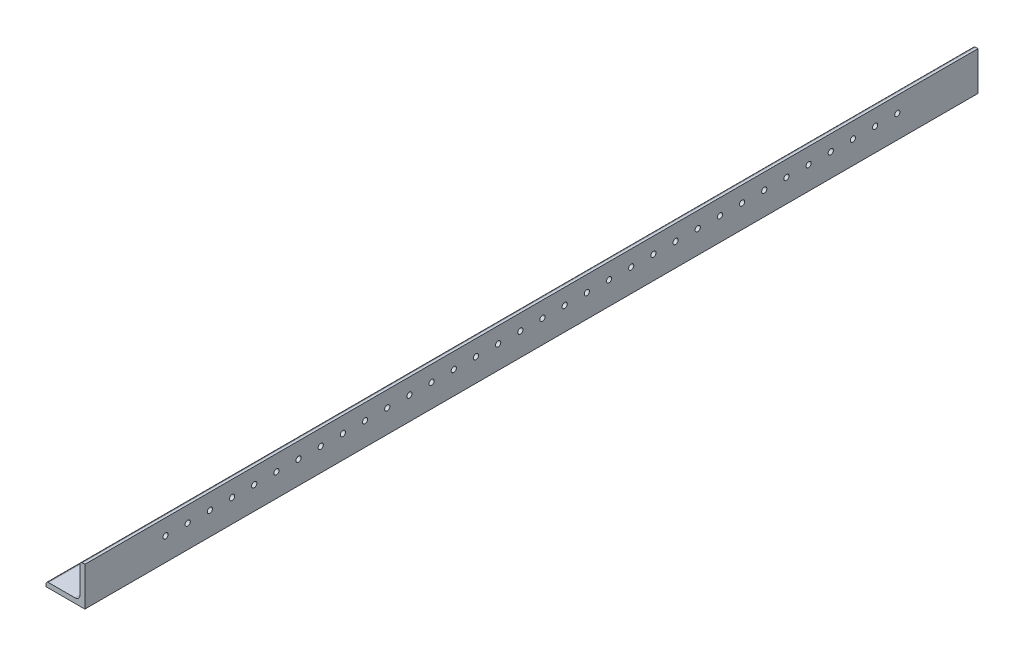
from build123d import *

# Parameters (mm, degrees)
BOSS_EXTRUDE1_DEPTH = 609.6
SKETCH3_W           = 635.2
SKETCH3_H           = 25.4
CUT_EXTRUDE2_DEPTH  = 30.48
SKETCH5_R           = 1.7
CUT_EXTRUDE3_DEPTH  = 611.137198198
SKETCH7_R           = 1.7
CUT_EXTRUDE4_DEPTH  = 611.137198198


with BuildPart() as part:
    # Sketch2 → Boss-Extrude1 (new, symmetric)
    with BuildSketch(Plane.XY):
        with BuildLine():
            Line((-12.7, -12.7), (12.7, -12.7))
            Line((12.7, -12.7), (12.7, 12.7))
            Line((12.7, 12.7), (11.1125, 12.7))
            ThreePointArc((11.1125, 12.7), (9.989967985, 12.235032015), (9.525, 11.1125))
            Line((9.525, 11.1125), (9.525, -6.35))
            ThreePointArc((9.525, -6.35), (8.59506403, -8.59506403), (6.35, -9.525))
            Line((6.35, -9.525), (-11.1125, -9.525))
            ThreePointArc((-11.1125, -9.525), (-12.235032015, -9.989967985), (-12.7, -11.1125))
            Line((-12.7, -11.1125), (-12.7, -12.7))
        make_face()
    extrude(amount=BOSS_EXTRUDE1_DEPTH, both=True)

    # Sketch3 → Cut-Extrude2 (cut)
    with BuildSketch(Plane(origin=(12.7, 0, 0), x_dir=(0, 0, -1), z_dir=(1, 0, 0))):
        with Locations((292, 0)):
            Rectangle(SKETCH3_W, SKETCH3_H)
    extrude(amount=-CUT_EXTRUDE2_DEPTH, mode=Mode.SUBTRACT)

    # Sketch5 → Cut-Extrude3 (cut, through all)
    with BuildSketch(Plane.ZY.offset(-9.525)):
        with Locations(Location((78.35, 2.38125, 0), (0, 0, 270))):
            Circle(SKETCH5_R)
        with Locations(Location((92.85, 2.38125, 0), (0, 0, 270))):
            Circle(SKETCH5_R)
        with Locations(Location((107.35, 2.38125, 0), (0, 0, 270))):
            Circle(SKETCH5_R)
        with Locations(Location((121.85, 2.38125, 0), (0, 0, 270))):
            Circle(SKETCH5_R)
        with Locations(Location((136.35, 2.38125, 0), (0, 0, 270))):
            Circle(SKETCH5_R)
        with Locations(Location((150.85, 2.38125, 0), (0, 0, 270))):
            Circle(SKETCH5_R)
        with Locations(Location((165.35, 2.38125, 0), (0, 0, 270))):
            Circle(SKETCH5_R)
        with Locations(Location((179.85, 2.38125, 0), (0, 0, 270))):
            Circle(SKETCH5_R)
        with Locations(Location((194.35, 2.38125, 0), (0, 0, 270))):
            Circle(SKETCH5_R)
        with Locations(Location((208.85, 2.38125, 0), (0, 0, 270))):
            Circle(SKETCH5_R)
        with Locations(Location((223.35, 2.38125, 0), (0, 0, 270))):
            Circle(SKETCH5_R)
        with Locations(Location((237.85, 2.38125, 0), (0, 0, 270))):
            Circle(SKETCH5_R)
        with Locations(Location((252.35, 2.38125, 0), (0, 0, 270))):
            Circle(SKETCH5_R)
        with Locations(Location((266.85, 2.38125, 0), (0, 0, 270))):
            Circle(SKETCH5_R)
        with Locations(Location((281.35, 2.38125, 0), (0, 0, 270))):
            Circle(SKETCH5_R)
        with Locations(Location((295.85, 2.38125, 0), (0, 0, 270))):
            Circle(SKETCH5_R)
        with Locations(Location((310.35, 2.38125, 0), (0, 0, 270))):
            Circle(SKETCH5_R)
        with Locations(Location((324.85, 2.38125, 0), (0, 0, 270))):
            Circle(SKETCH5_R)
        with Locations(Location((339.35, 2.38125, 0), (0, 0, 270))):
            Circle(SKETCH5_R)
        with Locations(Location((353.85, 2.38125, 0), (0, 0, 270))):
            Circle(SKETCH5_R)
        with Locations(Location((368.35, 2.38125, 0), (0, 0, 270))):
            Circle(SKETCH5_R)
        with Locations(Location((382.85, 2.38125, 0), (0, 0, 270))):
            Circle(SKETCH5_R)
        with Locations(Location((397.35, 2.38125, 0), (0, 0, 270))):
            Circle(SKETCH5_R)
        with Locations(Location((411.85, 2.38125, 0), (0, 0, 270))):
            Circle(SKETCH5_R)
        with Locations(Location((426.35, 2.38125, 0), (0, 0, 270))):
            Circle(SKETCH5_R)
        with Locations(Location((440.85, 2.38125, 0), (0, 0, 270))):
            Circle(SKETCH5_R)
        with Locations(Location((455.35, 2.38125, 0), (0, 0, 270))):
            Circle(SKETCH5_R)
        with Locations(Location((469.85, 2.38125, 0), (0, 0, 270))):
            Circle(SKETCH5_R)
        with Locations(Location((484.35, 2.38125, 0), (0, 0, 270))):
            Circle(SKETCH5_R)
        with Locations(Location((498.85, 2.38125, 0), (0, 0, 270))):
            Circle(SKETCH5_R)
        with Locations(Location((513.35, 2.38125, 0), (0, 0, 270))):
            Circle(SKETCH5_R)
        with Locations(Location((527.85, 2.38125, 0), (0, 0, 270))):
            Circle(SKETCH5_R)
        with Locations(Location((542.35, 2.38125, 0), (0, 0, 270))):
            Circle(SKETCH5_R)
        with Locations(Location((556.85, 2.38125, 0), (0, 0, 270))):
            Circle(SKETCH5_R)
    extrude(amount=-CUT_EXTRUDE3_DEPTH, mode=Mode.SUBTRACT)

    # Sketch7 → Cut-Extrude4 (cut, through all)
    with BuildSketch(Plane(origin=(0, -9.525, 0), x_dir=(1, 0, 0), z_dir=(0, 1, 0))):
        with Locations(Location((-2.38125, -78.35, 0), (0, 0, 180))):
            Circle(SKETCH7_R)
        with Locations(Location((-2.38125, -92.85, 0), (0, 0, 180))):
            Circle(SKETCH7_R)
        with Locations(Location((-2.38125, -107.35, 0), (0, 0, 180))):
            Circle(SKETCH7_R)
        with Locations(Location((-2.38125, -121.85, 0), (0, 0, 180))):
            Circle(SKETCH7_R)
        with Locations(Location((-2.38125, -136.35, 0), (0, 0, 180))):
            Circle(SKETCH7_R)
        with Locations(Location((-2.38125, -150.85, 0), (0, 0, 180))):
            Circle(SKETCH7_R)
        with Locations(Location((-2.38125, -165.35, 0), (0, 0, 180))):
            Circle(SKETCH7_R)
        with Locations(Location((-2.38125, -179.85, 0), (0, 0, 180))):
            Circle(SKETCH7_R)
        with Locations(Location((-2.38125, -194.35, 0), (0, 0, 180))):
            Circle(SKETCH7_R)
        with Locations(Location((-2.38125, -208.85, 0), (0, 0, 180))):
            Circle(SKETCH7_R)
        with Locations(Location((-2.38125, -223.35, 0), (0, 0, 180))):
            Circle(SKETCH7_R)
        with Locations(Location((-2.38125, -237.85, 0), (0, 0, 180))):
            Circle(SKETCH7_R)
        with Locations(Location((-2.38125, -252.35, 0), (0, 0, 180))):
            Circle(SKETCH7_R)
        with Locations(Location((-2.38125, -266.85, 0), (0, 0, 180))):
            Circle(SKETCH7_R)
        with Locations(Location((-2.38125, -281.35, 0), (0, 0, 180))):
            Circle(SKETCH7_R)
        with Locations(Location((-2.38125, -295.85, 0), (0, 0, 180))):
            Circle(SKETCH7_R)
        with Locations(Location((-2.38125, -310.35, 0), (0, 0, 180))):
            Circle(SKETCH7_R)
        with Locations(Location((-2.38125, -324.85, 0), (0, 0, 180))):
            Circle(SKETCH7_R)
        with Locations(Location((-2.38125, -339.35, 0), (0, 0, 180))):
            Circle(SKETCH7_R)
        with Locations(Location((-2.38125, -353.85, 0), (0, 0, 180))):
            Circle(SKETCH7_R)
        with Locations(Location((-2.38125, -368.35, 0), (0, 0, 180))):
            Circle(SKETCH7_R)
        with Locations(Location((-2.38125, -382.85, 0), (0, 0, 180))):
            Circle(SKETCH7_R)
        with Locations(Location((-2.38125, -397.35, 0), (0, 0, 180))):
            Circle(SKETCH7_R)
        with Locations(Location((-2.38125, -411.85, 0), (0, 0, 180))):
            Circle(SKETCH7_R)
        with Locations(Location((-2.38125, -426.35, 0), (0, 0, 180))):
            Circle(SKETCH7_R)
        with Locations(Location((-2.38125, -440.85, 0), (0, 0, 180))):
            Circle(SKETCH7_R)
        with Locations(Location((-2.38125, -455.35, 0), (0, 0, 180))):
            Circle(SKETCH7_R)
        with Locations(Location((-2.38125, -469.85, 0), (0, 0, 180))):
            Circle(SKETCH7_R)
        with Locations(Location((-2.38125, -484.35, 0), (0, 0, 180))):
            Circle(SKETCH7_R)
        with Locations(Location((-2.38125, -498.85, 0), (0, 0, 180))):
            Circle(SKETCH7_R)
        with Locations(Location((-2.38125, -513.35, 0), (0, 0, 180))):
            Circle(SKETCH7_R)
        with Locations(Location((-2.38125, -527.85, 0), (0, 0, 180))):
            Circle(SKETCH7_R)
        with Locations(Location((-2.38125, -542.35, 0), (0, 0, 180))):
            Circle(SKETCH7_R)
        with Locations(Location((-2.38125, -556.85, 0), (0, 0, 180))):
            Circle(SKETCH7_R)
    extrude(amount=-CUT_EXTRUDE4_DEPTH, mode=Mode.SUBTRACT)


solid = part.part
